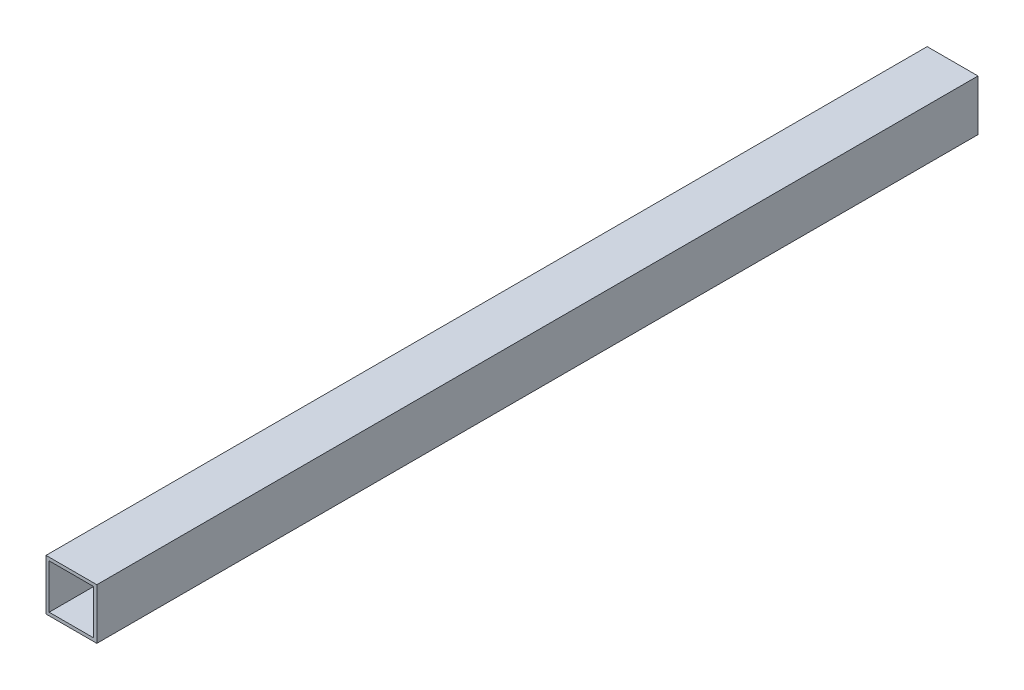
from build123d import *

# Parameters (mm, degrees)
SKETCH1_W           = 76.2
SKETCH1_H           = 76.2
SKETCH1_W_2         = 66.675
SKETCH1_H_2         = 66.675
BOSS_EXTRUDE1_DEPTH = 1320.8


with BuildPart() as part:
    # Sketch1 → Boss-Extrude1 (new body)
    with BuildSketch(Plane.XY):
        Rectangle(SKETCH1_W, SKETCH1_H)
        Rectangle(SKETCH1_W_2, SKETCH1_H_2, mode=Mode.SUBTRACT)
    extrude(amount=BOSS_EXTRUDE1_DEPTH)


solid = part.part
